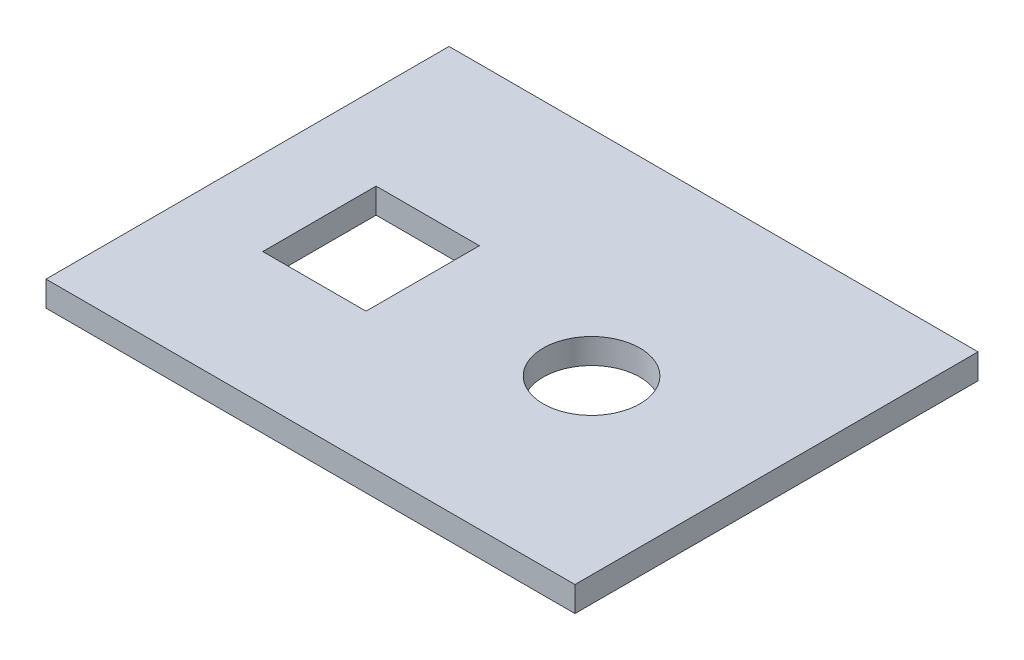
from build123d import *

# Parameters (mm, degrees)
SKETCH2_W               = 210
SKETCH2_H               = 160
BOSS_EXTRUDE1_DEPTH     = 10
SKETCH3_R               = 19.2
SKETCH3_W               = 41
SKETCH3_H               = 45
CUT_EXTRUDE2_DEPTH      = 15
CUT_EXTRUDE2_DEPTH_BACK = 22


with BuildPart() as part:
    # Sketch2 → Boss-Extrude1 (new body)
    with BuildSketch(Plane(origin=(0, 0, 0), x_dir=(1, 0, 0), z_dir=(0, 1, 0))):
        with Locations((5, 5)):
            Rectangle(SKETCH2_W, SKETCH2_H)
    extrude(amount=BOSS_EXTRUDE1_DEPTH)

    # Sketch3 → Cut-Extrude2 (cut, two sides)
    with BuildSketch(Plane(origin=(0, 0, 0), x_dir=(1, 0, 0), z_dir=(0, 1, 0))) as cut_extrude2_sk:
        with Locations((41.585, 0)):
            Circle(SKETCH3_R)
        with Locations((-45.952707493, 0)):
            Rectangle(SKETCH3_W, SKETCH3_H)
    extrude(amount=CUT_EXTRUDE2_DEPTH, mode=Mode.SUBTRACT)
    extrude(cut_extrude2_sk.sketch, amount=-CUT_EXTRUDE2_DEPTH_BACK, mode=Mode.SUBTRACT)


solid = part.part
